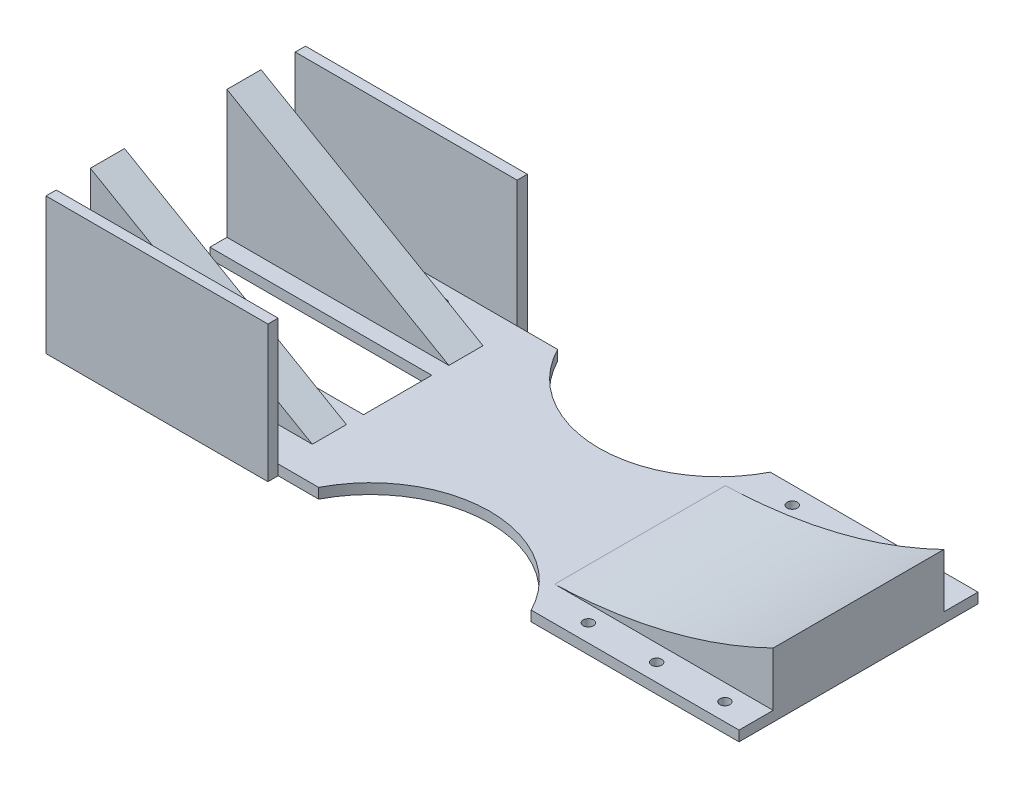
from build123d import *

# Parameters (mm, degrees)
SKETCH_1_W           = 200
SKETCH_1_H           = 70
EXTRUDE_1_DEPTH      = 3
EXTRUDE_2_DEPTH      = 25
EXTRUDE_2_DEPTH_BACK = 25
SKETCH_6_W           = 30
SKETCH_6_H           = 37.527767497
CUT_EXTRUDE_4_DEPTH  = 65
SKETCH_7_R           = 35
CUT_EXTRUDE_5_DEPTH  = 4
SKETCH_8_W           = 3
SKETCH_8_H           = 40
EXTRUDE_3_DEPTH      = 65
SKETCH_9_R           = 1.5
CUT_EXTRUDE_6_DEPTH  = 4
SKETCH_11_W          = 65
SKETCH_11_H          = 20
CUT_EXTRUDE_7_DEPTH  = 4


with BuildPart() as part:
    # 草图1 → 凸台-拉伸1 (new body)
    with BuildSketch(Plane(origin=(0, 0, 0), x_dir=(1, 0, 0), z_dir=(0, 1, 0))):
        with Locations((17.295373665, 0)):
            Rectangle(SKETCH_1_W, SKETCH_1_H)
    extrude(amount=EXTRUDE_1_DEPTH)

    # 草图2 → 凸台-拉伸2 (add, two sides)
    with BuildSketch(Plane.XY) as extrude_2_sk:
        Polygon((-82.704626335, 40.527767497), (-82.704626335, 3), (-17.704626335, 3), align=None)
        with BuildLine():
            Line((117.295373665, 3), (117.295373665, 18.810437945))
            add(Edge.make_bspline(
                [(53.295373665, 3), (87.19337421, 4.102292249), (117.295373665, 18.810437945)],
                knots=[0, 0, 0, 1, 1, 1], degree=2))
            Line((53.295373665, 3), (117.295373665, 3))
        make_face()
    extrude(amount=EXTRUDE_2_DEPTH)
    extrude(extrude_2_sk.sketch, amount=-EXTRUDE_2_DEPTH_BACK)

    # 草图6 → 切除-拉伸4 (cut)
    with BuildSketch(Plane.ZY.offset(82.704626335)):
        with Locations((0, 21.763883748)):
            Rectangle(SKETCH_6_W, SKETCH_6_H)
    extrude(amount=-CUT_EXTRUDE_4_DEPTH, mode=Mode.SUBTRACT)

    # 草图7 → 切除-拉伸5 (cut, through all)
    with BuildSketch(Plane(origin=(0, 3, 0), x_dir=(1, 0, 0), z_dir=(0, 1, 0))):
        with Locations((25.295373665, 51)):
            Circle(SKETCH_7_R)
        with Locations((25.295373665, -51)):
            Circle(SKETCH_7_R)
    extrude(amount=-CUT_EXTRUDE_5_DEPTH, mode=Mode.SUBTRACT)

    # 草图8 → 凸台-拉伸3 (add)
    with BuildSketch(Plane.ZY.offset(82.704626335)):
        with Locations((36.5, 20)):
            Rectangle(SKETCH_8_W, SKETCH_8_H)
        with Locations((-36.5, 20)):
            Rectangle(SKETCH_8_W, SKETCH_8_H)
    extrude(amount=-EXTRUDE_3_DEPTH)

    # 草图9 → 切除-拉伸6 (cut, through all)
    with BuildSketch(Plane(origin=(0, 3, 0), x_dir=(1, 0, 0), z_dir=(0, 1, 0))):
        with Locations((-74.766784803, 29.860059225)):
            Circle(SKETCH_9_R)
        with Locations((-54.766784803, 29.860059225)):
            Circle(SKETCH_9_R)
        with Locations((-34.766784803, 29.860059225)):
            Circle(SKETCH_9_R)
        with Locations((-34.766784803, -29.860059225)):
            Circle(SKETCH_9_R)
        with Locations((-54.766784803, -29.860059225)):
            Circle(SKETCH_9_R)
        with Locations((-74.766784803, -29.860059225)):
            Circle(SKETCH_9_R)
        with Locations((68.031562246, 29.860059225)):
            Circle(SKETCH_9_R)
        with Locations((88.031562246, 29.860059225)):
            Circle(SKETCH_9_R)
        with Locations((108.031562246, 29.860059225)):
            Circle(SKETCH_9_R)
        with Locations((108.031562246, -29.860059225)):
            Circle(SKETCH_9_R)
        with Locations((88.031562246, -29.860059225)):
            Circle(SKETCH_9_R)
        with Locations((68.031562246, -29.860059225)):
            Circle(SKETCH_9_R)
    extrude(amount=-CUT_EXTRUDE_6_DEPTH, mode=Mode.SUBTRACT)

    # 草图11 → 切除-拉伸7 (cut, through all)
    with BuildSketch(Plane(origin=(0, 3, 0), x_dir=(1, 0, 0), z_dir=(0, 1, 0))):
        with Locations((-50.204626335, 0)):
            Rectangle(SKETCH_11_W, SKETCH_11_H)
    extrude(amount=-CUT_EXTRUDE_7_DEPTH, mode=Mode.SUBTRACT)


solid = part.part
